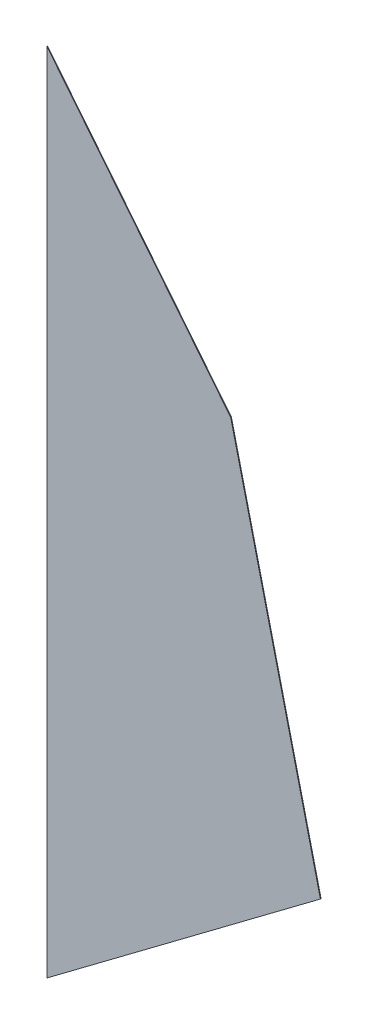
from build123d import *

# Parameters (mm, degrees)
BOSS_EXTRUDE1_DEPTH = 2.54


with BuildPart() as part:
    # Sketch1 → Boss-Extrude1 (new body)
    with BuildSketch(Plane.XY):
        Polygon((0, 0), (1016, 762), (682.945007657, 2144.857958026), (0, 2997.2), align=None)
    extrude(amount=BOSS_EXTRUDE1_DEPTH)


solid = part.part
